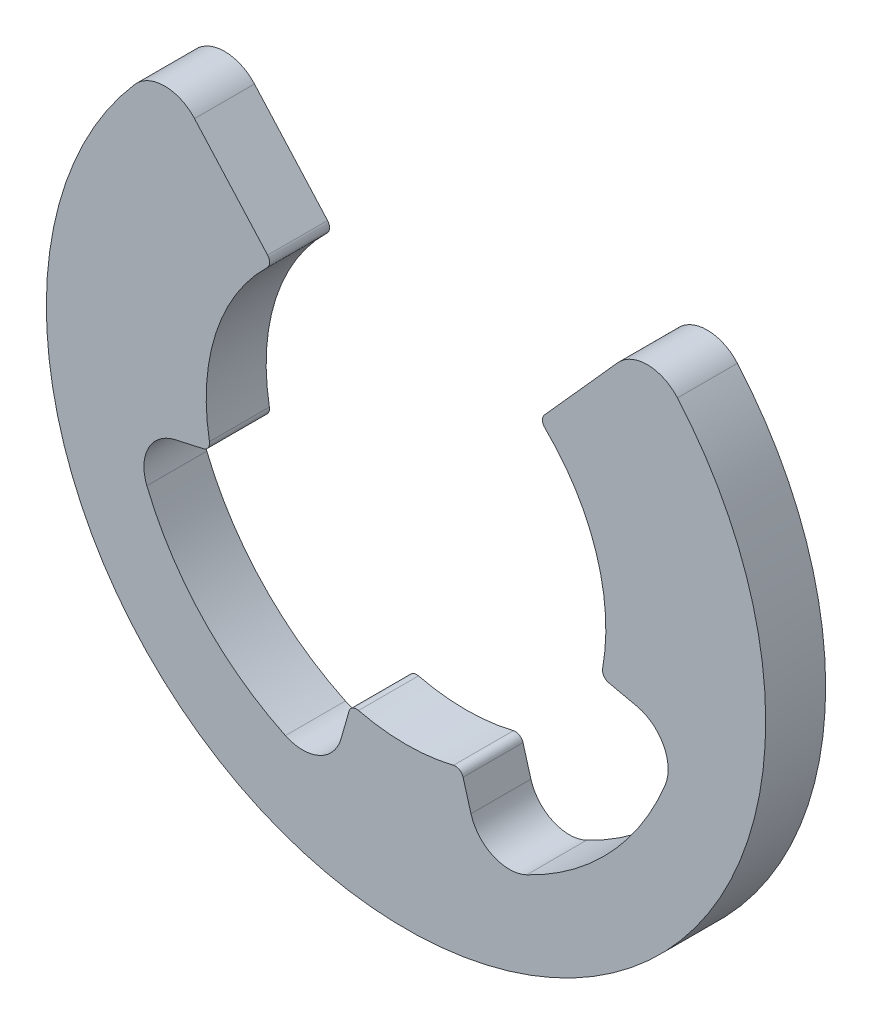
from build123d import *

# Parameters (mm, degrees)
ESTRUSIONE_ESTRUSIONE1_DEPTH = 0.75


with BuildPart() as part:
    # Schizzo1 → Estrusione-Estrusione1 (new body)
    with BuildSketch(Plane.XY):
        with BuildLine():
            Line((0.713746427, -2.498112495), (0.812636055, -2.844226194))
            ThreePointArc((0.812636055, -2.844226194), (1.087978373, -3.162719515), (1.508964367, -3.158009901))
            ThreePointArc((1.508964367, -3.158009901), (2.5475521, -2.399995479), (3.24232421, -1.318079558))
            ThreePointArc((3.24232421, -1.318079558), (3.221936632, -0.897561146), (2.887600266, -0.641688948))
            Line((2.887600266, -0.641688948), (2.536208379, -0.563601862))
            ThreePointArc((2.536208379, -0.563601862), (2.474583527, -0.521283499), (2.459520601, -0.448060727))
            ThreePointArc((2.459520601, -0.448060727), (2.37991714, 0.765502714), (1.737102314, 1.79790866))
            ThreePointArc((1.737102314, 1.79790866), (1.706652775, 1.866182313), (1.732050808, 1.936491673))
            Line((1.732050808, 1.936491673), (2.645751311, 2.958039892))
            ThreePointArc((2.645751311, 2.958039892), (3.021925983, 3.124694331), (3.395732971, 2.952794878))
            ThreePointArc((3.395732971, 2.952794878), (0, -4.5), (-3.395732971, 2.952794878))
            ThreePointArc((-3.395732971, 2.952794878), (-3.021925983, 3.124694331), (-2.645751311, 2.958039892))
            Line((-2.645751311, 2.958039892), (-1.732050808, 1.936491673))
            ThreePointArc((-1.732050808, 1.936491673), (-1.706652775, 1.866182313), (-1.737102314, 1.79790866))
            ThreePointArc((-1.737102314, 1.79790866), (-2.37991714, 0.765502714), (-2.459520601, -0.448060727))
            ThreePointArc((-2.459520601, -0.448060727), (-2.474583527, -0.521283499), (-2.536208379, -0.563601862))
            Line((-2.536208379, -0.563601862), (-2.887600266, -0.641688948))
            ThreePointArc((-2.887600266, -0.641688948), (-3.221936632, -0.897561146), (-3.24232421, -1.318079558))
            ThreePointArc((-3.24232421, -1.318079558), (-2.5475521, -2.399995479), (-1.508964367, -3.158009901))
            ThreePointArc((-1.508964367, -3.158009901), (-1.087978373, -3.162719515), (-0.812636055, -2.844226194))
            Line((-0.812636055, -2.844226194), (-0.713746427, -2.498112495))
            ThreePointArc((-0.713746427, -2.498112495), (-0.667830724, -2.439119153), (-0.593840416, -2.428446738))
            ThreePointArc((-0.593840416, -2.428446738), (0, -2.5), (0.593840416, -2.428446738))
            ThreePointArc((0.593840416, -2.428446738), (0.667830724, -2.439119153), (0.713746427, -2.498112495))
        make_face()
    extrude(amount=ESTRUSIONE_ESTRUSIONE1_DEPTH)


solid = part.part
